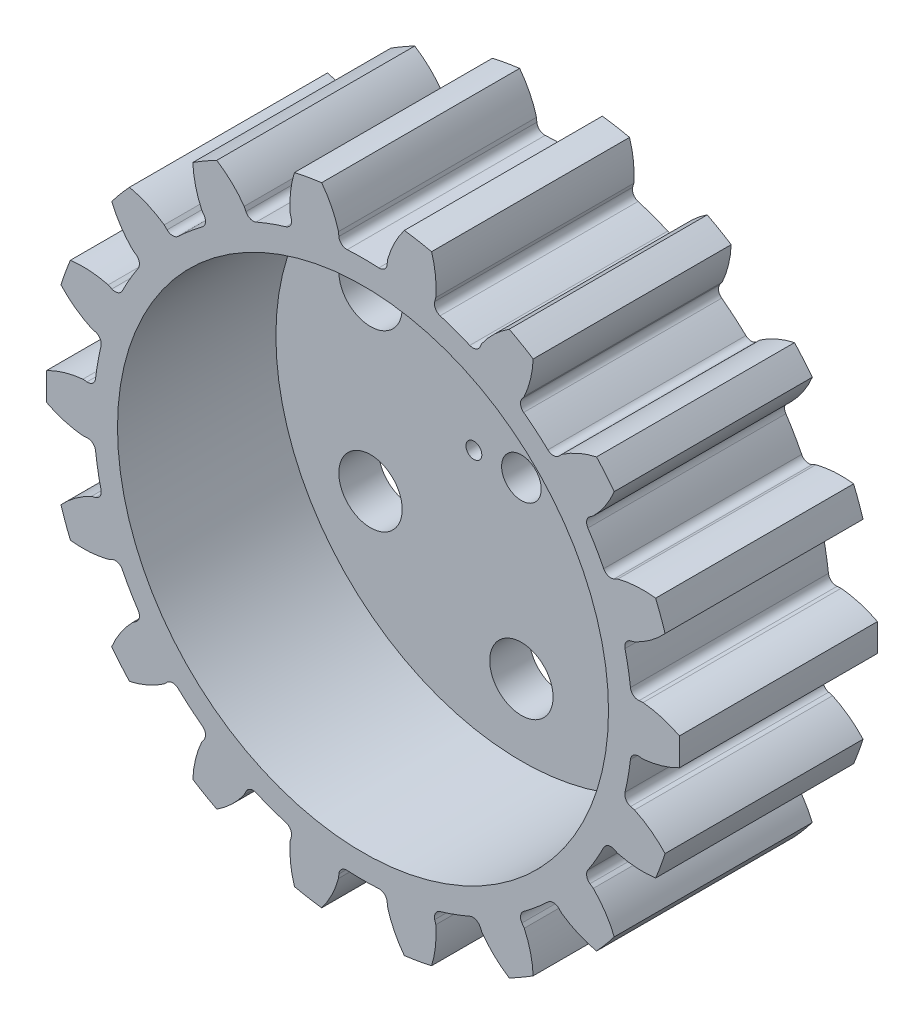
from build123d import *

# Parameters (mm, degrees)
BOSS_EXTRU_1_DEPTH                 = 25
CONG_1_R                           = 1
R_P_TITION_CIRCULAIRE2_COUNT       = 18
CONG_1_OF_R_P_TITION_CIRCULAIRE2_R = 1
ESQUISSE10_R                       = 2.5
ENL_V_MAT_EXTRU_6_DEPTH            = 25
ESQUISSE11_R                       = 31
ENL_V_MAT_EXTRU_7_DEPTH            = 20
ESQUISSE12_R                       = 1
ENL_V_MAT_EXTRU_8_DEPTH            = 5
ESQUISSE9_R                        = 4
ENL_V_MAT_EXTRU_5_DEPTH            = 25
R_P_TITION_CIRCULAIRE3_COUNT       = 6


with BuildPart() as part:
    # Esquisse1 → Boss.-Extru.1 (new body)
    with BuildSketch(Plane.XY):
        with BuildLine():
            Line((33.870619735, -2.963295253), (35.364911782, -3.094028868))
            ThreePointArc((35.364911782, -3.094028868), (37.724726959, -2.640126003), (39.954644748, -1.744457463))
            ThreePointArc((39.954644748, -1.744457463), (39.992708945, 0), (39.954644748, 1.744457463))
            ThreePointArc((39.954644748, 1.744457463), (37.724726959, 2.640126003), (35.364911782, 3.094028868))
            Line((35.364911782, 3.094028868), (33.870619735, 2.963295253))
            ThreePointArc((33.870619735, 2.963295253), (33.709125287, 4.437890535), (33.483463602, 5.904038041))
            Line((33.483463602, 5.904038041), (0, 0))
            Line((0, 0), (33.483463602, -5.904038041))
            ThreePointArc((33.483463602, -5.904038041), (33.709125287, -4.437890535), (33.870619735, -2.963295253))
        make_face()
    boss_extru_1 = extrude(amount=BOSS_EXTRU_1_DEPTH)

    # Congé1
    cong_1_edges = [part.edges().sort_by_distance(p)[0] for p in [
        (33.870619735, -2.963295253, 12.5),
        (33.870619735, 2.963295253, 12.5),
    ]]
    fillet(cong_1_edges, radius=CONG_1_R)

    # Répétition circulaire2: Boss.-Extru.1 ×18 about axis
    r_p_tition_circulaire2_axis = Axis((0, 0, 0), (0, 0, 1))
    for i in range(1, R_P_TITION_CIRCULAIRE2_COUNT):
        add(boss_extru_1.rotate(r_p_tition_circulaire2_axis, i * 360 / R_P_TITION_CIRCULAIRE2_COUNT))

    # Congé1 of Répétition circulaire2
    cong_1_of_r_p_tition_circulaire2_edges = [part.edges().sort_by_distance(p)[0] for p in [
        (32.841478094, 8.799847533, 12.5),
        (30.814464759, 14.369020899, 12.5),
        (27.851169506, 19.501598836, 12.5),
        (24.04163056, 24.04163056, 12.5),
        (19.501598836, 27.851169506, 12.5),
        (14.369020899, 30.814464759, 12.5),
        (8.799847533, 32.841478094, 12.5),
        (2.963295253, 33.870619735, 12.5),
        (-2.963295253, 33.870619735, 12.5),
        (-8.799847533, 32.841478094, 12.5),
        (-14.369020899, 30.814464759, 12.5),
        (-19.501598836, 27.851169506, 12.5),
        (-24.04163056, 24.04163056, 12.5),
        (-27.851169506, 19.501598836, 12.5),
        (-30.814464759, 14.369020899, 12.5),
        (-32.841478094, 8.799847533, 12.5),
        (-33.870619735, 2.963295253, 12.5),
        (-33.870619735, -2.963295253, 12.5),
        (-32.841478094, -8.799847533, 12.5),
        (-30.814464759, -14.369020899, 12.5),
        (-27.851169506, -19.501598836, 12.5),
        (-24.04163056, -24.04163056, 12.5),
        (-19.501598836, -27.851169506, 12.5),
        (-14.369020899, -30.814464759, 12.5),
        (-8.799847533, -32.841478094, 12.5),
        (-2.963295253, -33.870619735, 12.5),
        (2.963295253, -33.870619735, 12.5),
        (8.799847533, -32.841478094, 12.5),
        (14.369020899, -30.814464759, 12.5),
        (19.501598836, -27.851169506, 12.5),
        (24.04163056, -24.04163056, 12.5),
        (27.851169506, -19.501598836, 12.5),
        (30.814464759, -14.369020899, 12.5),
        (32.841478094, -8.799847533, 12.5),
    ]]
    fillet(cong_1_of_r_p_tition_circulaire2_edges, radius=CONG_1_OF_R_P_TITION_CIRCULAIRE2_R)

    # Esquisse10 → Enlèv. mat.-Extru.6 (cut)
    with BuildSketch(Plane.XY.offset(25)):
        Circle(ESQUISSE10_R)
    extrude(amount=-ENL_V_MAT_EXTRU_6_DEPTH, mode=Mode.SUBTRACT)

    # Esquisse11 → Enlèv. mat.-Extru.7 (cut)
    with BuildSketch(Plane.XY.offset(25)):
        Circle(ESQUISSE11_R)
    extrude(amount=-ENL_V_MAT_EXTRU_7_DEPTH, mode=Mode.SUBTRACT)

    # Esquisse12 → Enlèv. mat.-Extru.8 (cut)
    with BuildSketch(Plane(origin=(0, 0, 0), x_dir=(-1, 0, 0), z_dir=(0, 0, -1))):
        with Locations((-6, 0)):
            Circle(ESQUISSE12_R)
        with Locations((6, 0)):
            Circle(ESQUISSE12_R)
    extrude(amount=-ENL_V_MAT_EXTRU_8_DEPTH, mode=Mode.SUBTRACT)

    # Esquisse9 → Enlèv. mat.-Extru.5 (cut)
    with BuildSketch(Plane.XY.offset(25)):
        with Locations((0, 22)):
            Circle(ESQUISSE9_R)
    enl_v_mat_extru_5 = extrude(amount=-ENL_V_MAT_EXTRU_5_DEPTH, mode=Mode.SUBTRACT)

    # Répétition circulaire3: Enlèv. mat.-Extru.5 ×6 about axis
    r_p_tition_circulaire3_axis = Axis((0, 0, 0), (0, 0, 1))
    for i in range(1, R_P_TITION_CIRCULAIRE3_COUNT):
        add(enl_v_mat_extru_5.rotate(r_p_tition_circulaire3_axis, i * 360 / R_P_TITION_CIRCULAIRE3_COUNT), mode=Mode.SUBTRACT)


solid = part.part
